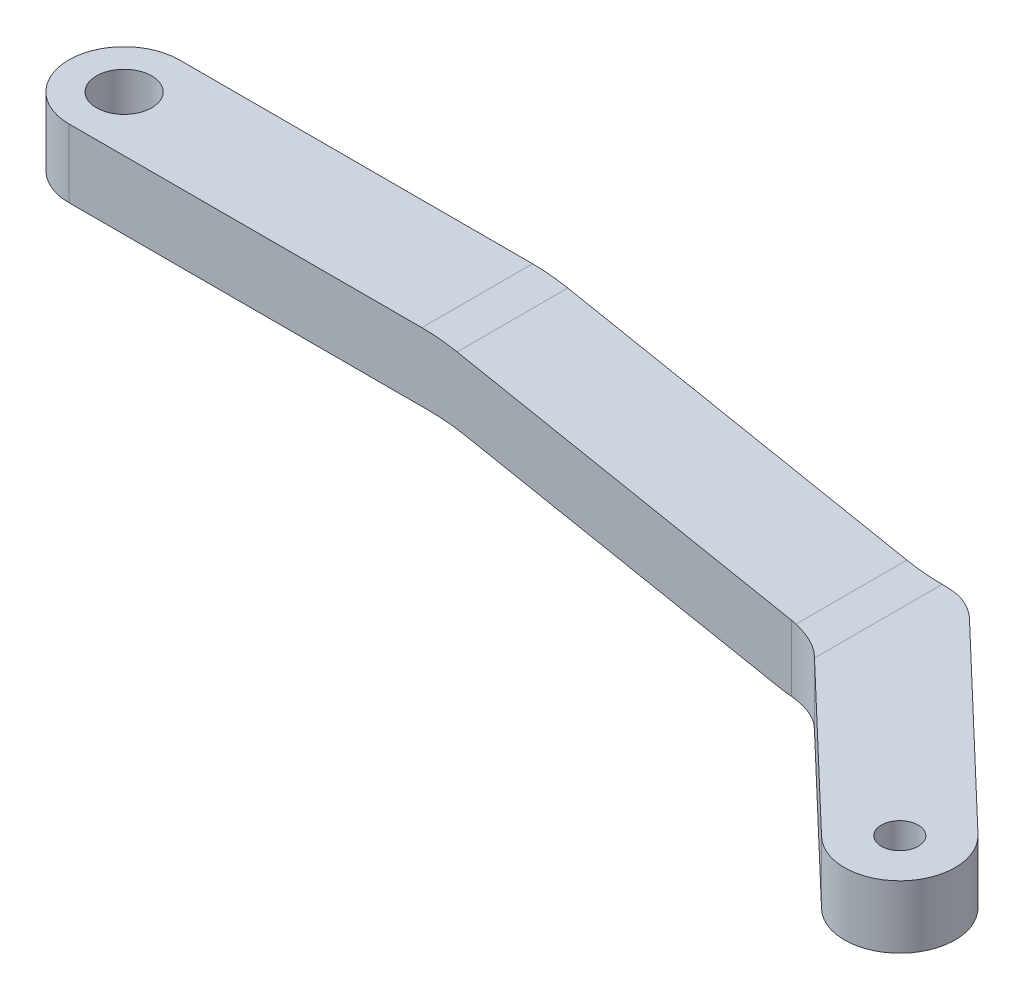
from build123d import *

# Parameters (mm, degrees)
BOSS_EXTRUDE1_DEPTH     = 3
BOSS_EXTRUDE2_DEPTH     = 3.4
CUT_EXTRUDE1_DEPTH      = 1
CUT_EXTRUDE1_DEPTH_BACK = 8.35
CUT_EXTRUDE2_DEPTH      = 10.948718941
CUT_EXTRUDE2_DEPTH_BACK = 7
SKETCH6_R               = 1.5
SKETCH6_R_2             = 1
CUT_EXTRUDE4_DEPTH      = 1
CUT_EXTRUDE4_DEPTH_BACK = 8.35
FILLET1_R               = 10
FILLET2_R               = 3


with BuildPart() as part:
    # Sketch1 → Boss-Extrude1 (new body, symmetric)
    with BuildSketch(Plane.XY):
        Polygon((-14.712036777, 3.95), (8.397963223, 3.95), (28.677963223, 0), (-14.712036777, 0), align=None)
    extrude(amount=BOSS_EXTRUDE1_DEPTH, both=True)

    # Sketch2 → Boss-Extrude2 (add)
    with BuildSketch(Plane.XZ):
        with BuildLine():
            Line((-11.712036777, -3), (31.08325999, -3))
            Line((31.08325999, -3), (42.367258396, 7.779455791))
            ThreePointArc((42.367258396, 7.779455791), (42.464252889, 12.020987598), (38.222721082, 12.117982091))
            Line((38.222721082, 12.117982091), (28.677963223, 3))
            Line((28.677963223, 3), (-11.712036777, 3))
            ThreePointArc((-11.712036777, 3), (-14.712036777, 0), (-11.712036777, -3))
        make_face()
    extrude(amount=BOSS_EXTRUDE2_DEPTH)

    # Sketch3 → Cut-Extrude1 (cut, two sides)
    with BuildSketch(Plane(origin=(0, 3.95, 0), x_dir=(1, 0, 0), z_dir=(0, 1, 0))) as cut_extrude1_sk:
        with BuildLine():
            ThreePointArc((-14.712036777, 0), (-13.833357121, 2.121320344), (-11.712036777, 3))
            Line((-11.712036777, 3), (-14.712036777, 3))
            Line((-14.712036777, 3), (-14.712036777, 0))
        make_face()
        with BuildLine():
            ThreePointArc((-11.712036777, -3), (-13.833357121, -2.121320344), (-14.712036777, 0))
            Line((-14.712036777, 0), (-14.712036777, -3))
            Line((-14.712036777, -3), (-11.712036777, -3))
        make_face()
    extrude(amount=CUT_EXTRUDE1_DEPTH, mode=Mode.SUBTRACT)
    extrude(cut_extrude1_sk.sketch, amount=-CUT_EXTRUDE1_DEPTH_BACK, mode=Mode.SUBTRACT)

    # Sketch4 → Cut-Extrude2 (cut, two sides)
    with BuildSketch(Plane.XY.offset(3)) as cut_extrude2_sk:
        Polygon((-14.712036777, 0.25), (8.825585542, 0.25), (27.565332378, -3.4), (-14.712036777, -3.4), align=None)
    extrude(amount=CUT_EXTRUDE2_DEPTH, mode=Mode.SUBTRACT)
    extrude(cut_extrude2_sk.sketch, amount=-CUT_EXTRUDE2_DEPTH_BACK, mode=Mode.SUBTRACT)

    # Sketch6 → Cut-Extrude4 (cut, two sides)
    with BuildSketch(Plane(origin=(0, 3.95, 0), x_dir=(1, 0, 0), z_dir=(0, 1, 0))) as cut_extrude4_sk:
        with Locations((-11.712036777, 0)):
            Circle(SKETCH6_R)
        with Locations((40.294989739, -9.948718941)):
            Circle(SKETCH6_R_2)
    extrude(amount=CUT_EXTRUDE4_DEPTH, mode=Mode.SUBTRACT)
    extrude(cut_extrude4_sk.sketch, amount=-CUT_EXTRUDE4_DEPTH_BACK, mode=Mode.SUBTRACT)

    # Fillet1
    fillet1_edges = [part.edges().sort_by_distance(p)[0] for p in [
        (8.397963223, 3.95, 0),
        (28.677963223, 0, 0),
        (27.565332378, -3.4, 0),
        (8.825585542, 0.25, 0),
    ]]
    fillet(fillet1_edges, radius=FILLET1_R)

    # Fillet2
    fillet2_edges = [part.edges().sort_by_distance(p)[0] for p in [
        (31.08325999, -1.7, -3),
        (28.677963223, -1.676674581, 3),
    ]]
    fillet(fillet2_edges, radius=FILLET2_R)


solid = part.part
